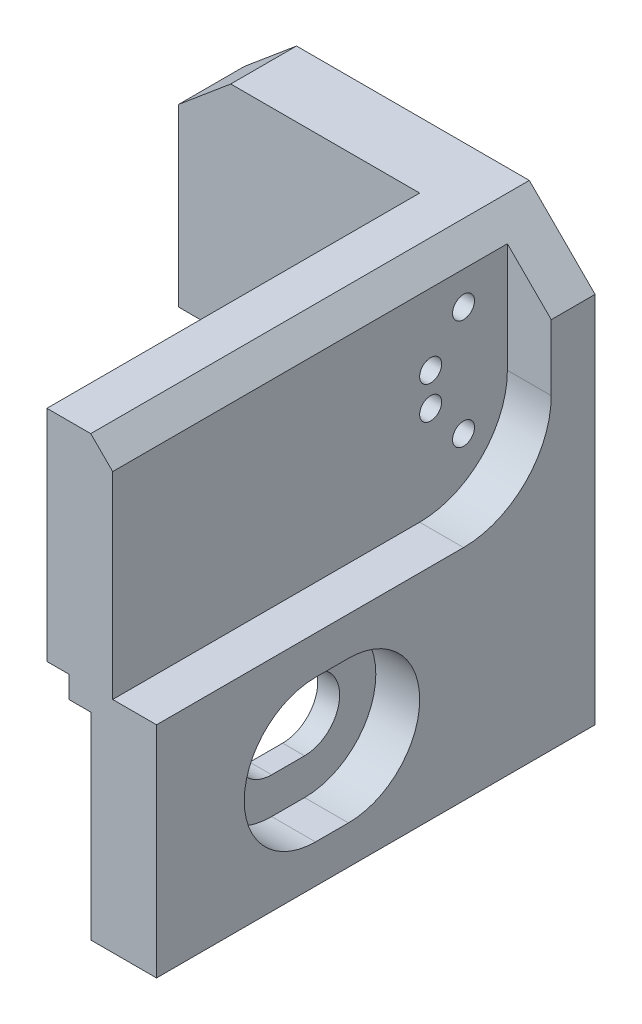
from build123d import *

# Parameters (mm, degrees)
EXTRUDE_1_DEPTH     = 20
SKETCH_2_W          = 17
SKETCH_2_H          = 10
CUT_EXTRUDE_1_DEPTH = 11
CUT_EXTRUDE_2_REACH = 18
CHAMFER_1_SIZE      = 3
CHAMFER_2_SIZE      = 2
CHAMFER_2_SIZE2     = 2.383507185
CUT_EXTRUDE_3_DEPTH = 2
CUT_EXTRUDE_4_DEPTH = 2
SKETCH_5_R          = 0.5
CUT_EXTRUDE_5_DEPTH = 6


with BuildPart() as part:
    # Эскиз1 → Бобышка-Вытянуть1 (new body)
    with BuildSketch(Plane.XY):
        Polygon((0, 0), (1, 0), (1, -9), (4, -9), (4, 11), (-12, 11), (-12, 1), (0, 1), align=None)
    extrude(amount=EXTRUDE_1_DEPTH)

    # Эскиз2 → Вырез-Вытянуть1 (cut)
    with BuildSketch(Plane.ZY.offset(12)):
        with Locations((11.5, 6)):
            Rectangle(SKETCH_2_W, SKETCH_2_H)
    extrude(amount=-CUT_EXTRUDE_1_DEPTH, mode=Mode.SUBTRACT)

    # Эскиз3 → Вырез-Вытянуть2 (cut, up to next)
    with BuildSketch(Plane(origin=(4, 0, 0), x_dir=(0, 0, -1), z_dir=(1, 0, 0)), mode=Mode.PRIVATE) as cut_extrude_2_sk1:
        with BuildLine():
            Line((-12.75, -2.4), (-11.25, -2.4))
            ThreePointArc((-11.25, -2.4), (-9.65, -4), (-11.25, -5.6))
            Line((-11.25, -5.6), (-12.75, -5.6))
            ThreePointArc((-12.75, -5.6), (-14.35, -4), (-12.75, -2.4))
        make_face()
    cut_extrude_2_tool1 = extrude(cut_extrude_2_sk1.sketch, amount=-CUT_EXTRUDE_2_REACH, mode=Mode.PRIVATE) & part.part
    add(cut_extrude_2_tool1.solids().sort_by_distance((4, -4, 12))[0], mode=Mode.SUBTRACT)

    # Фаска1
    chamfer_1_edges = [part.edges().sort_by_distance(p)[0] for p in [
        (4, 11, 10),
    ]]
    chamfer(chamfer_1_edges, length=CHAMFER_1_SIZE)

    # Фаска2
    chamfer_2_edges = [part.edges().sort_by_distance(p)[0] for p in [
        (-12, 11, 1.5),
    ]]
    chamfer_2_side = [part.faces().sort_by_distance(p)[0] for p in [
        (-12, 6, 1.5),
    ]]
    chamfer(chamfer_2_edges, length=CHAMFER_2_SIZE, length2=CHAMFER_2_SIZE2, reference=chamfer_2_side[0])

    # Эскиз3<3> → Вырез-Вытянуть3 (cut)
    with BuildSketch(Plane(origin=(4, 0, 0), x_dir=(0, 0, -1), z_dir=(1, 0, 0))):
        with BuildLine():
            Line((-12.75, -0.75), (-11.25, -0.75))
            ThreePointArc((-11.25, -0.75), (-8, -4), (-11.25, -7.25))
            Line((-11.25, -7.25), (-12.75, -7.25))
            ThreePointArc((-12.75, -7.25), (-16, -4), (-12.75, -0.75))
        make_face()
        with BuildLine():
            Line((-12.75, -2.4), (-11.25, -2.4))
            ThreePointArc((-11.25, -2.4), (-9.65, -4), (-11.25, -5.6))
            Line((-11.25, -5.6), (-12.75, -5.6))
            ThreePointArc((-12.75, -5.6), (-14.35, -4), (-12.75, -2.4))
        make_face(mode=Mode.SUBTRACT)
    extrude(amount=-CUT_EXTRUDE_3_DEPTH, mode=Mode.SUBTRACT)

    # Эскиз4 → Вырез-Вытянуть4 (cut)
    with BuildSketch(Plane(origin=(4, 0, 0), x_dir=(0, 0, -1), z_dir=(1, 0, 0))):
        with BuildLine():
            Line((-20, 1), (-6, 1))
            ThreePointArc((-6, 1), (-3.171572875, 2.171572875), (-2, 5))
            Line((-2, 5), (-2, 11))
            Line((-2, 11), (-20, 11))
            Line((-20, 11), (-20, 10))
            Line((-20, 10), (-20, 1))
        make_face()
    extrude(amount=-CUT_EXTRUDE_4_DEPTH, mode=Mode.SUBTRACT)

    # Эскиз5 → Вырез-Вытянуть5 (cut, through all)
    with BuildSketch(Plane.ZY.offset(1)):
        with Locations((4, 8.5)):
            Circle(SKETCH_5_R)
        with Locations((5.5, 6.75)):
            Circle(SKETCH_5_R)
        with Locations((5.5, 5.25)):
            Circle(SKETCH_5_R)
        with Locations((4, 3.5)):
            Circle(SKETCH_5_R)
    extrude(amount=-CUT_EXTRUDE_5_DEPTH, mode=Mode.SUBTRACT)


solid = part.part
